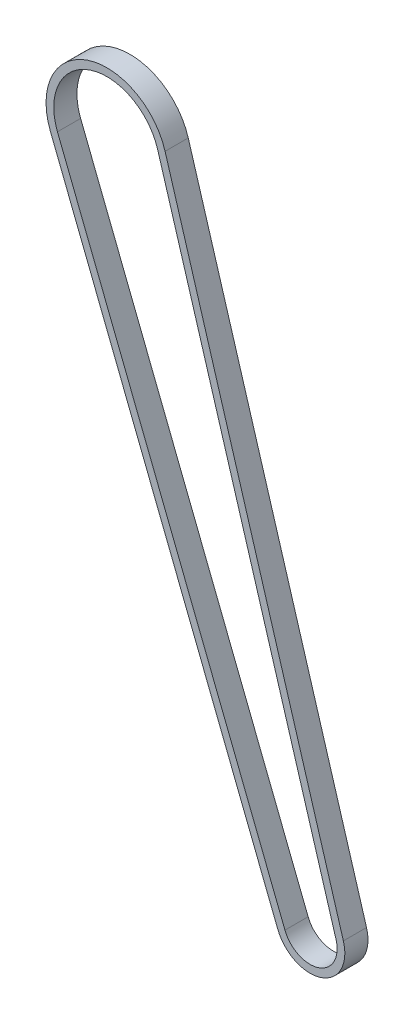
from build123d import *

# Parameters (mm, degrees)
EXTRU_MINCE1_START = 8.55
EXTRU_MINCE1_DEPTH = 6


with BuildPart() as part:
    # Esquisse2 → Extru.-Mince1 (new body)
    with BuildSketch(Plane.XY.offset(EXTRU_MINCE1_START)):
        with BuildLine():
            Line((-37.572335011, 156.648401465), (8.620835495, 2.584800837))
            ThreePointArc((8.620835495, 2.584800837), (2.944002228, -8.504872185), (-8.373949421, -3.298025333))
            Line((-8.373949421, -3.298025333), (-67.313208614, 146.353455668))
            ThreePointArc((-67.313208614, 146.353455668), (-57.810801026, 167.008526323), (-37.572335011, 156.648401465))
        make_face()
        with BuildLine():
            Line((-39.488076232, 156.074001279), (6.705094274, 2.010400651))
            ThreePointArc((6.705094274, 2.010400651), (2.289779511, -6.614900588), (-6.513071772, -2.565130814))
            Line((-6.513071772, -2.565130814), (-65.452330965, 147.086350186))
            ThreePointArc((-65.452330965, 147.086350186), (-57.156578309, 165.118554727), (-39.488076232, 156.074001279))
        make_face(mode=Mode.SUBTRACT)
    extrude(amount=EXTRU_MINCE1_DEPTH)


solid = part.part
